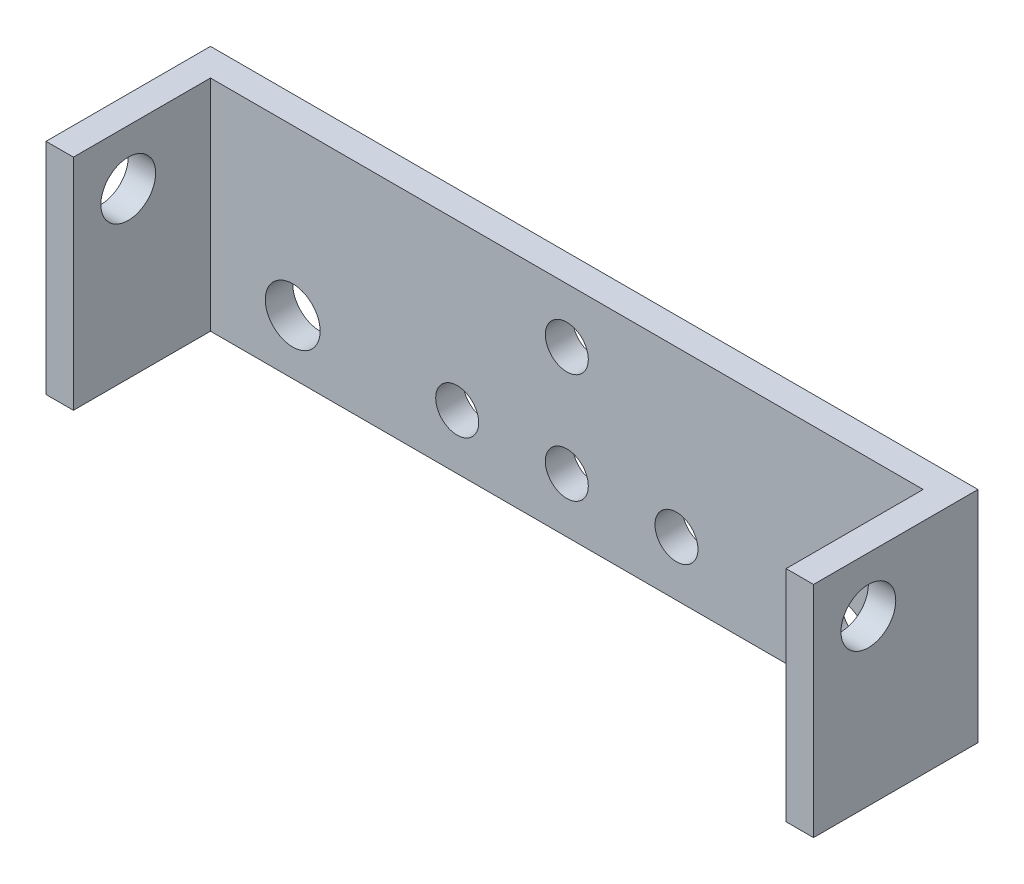
from build123d import *

# Parameters (mm, degrees)
BOSS_EXTRUDE1_DEPTH     = 25.4
SKETCH2_R               = 3.175
CUT_EXTRUDE1_DEPTH      = 89.9
SKETCH3_R               = 3.175
CUT_EXTRUDE2_DEPTH      = 16.875
CUT_EXTRUDE2_DEPTH_BACK = 4.175
SKETCH4_R               = 2.4892
CUT_EXTRUDE3_DEPTH      = 4.175
SKETCH5_R               = 2.4892
CUT_EXTRUDE4_DEPTH      = 20.05


with BuildPart() as part:
    # Sketch1 → Boss-Extrude1 (new body)
    with BuildSketch(Plane(origin=(0, 0, 0), x_dir=(1, 0, 0), z_dir=(0, 1, 0))):
        Polygon((0, 0), (0, 19.05), (88.9, 19.05), (88.9, 0), (85.725, 0), (85.725, 15.875), (3.175, 15.875), (3.175, 0), align=None)
    extrude(amount=BOSS_EXTRUDE1_DEPTH)

    # Sketch2 → Cut-Extrude1 (cut, through all)
    with BuildSketch(Plane(origin=(88.9, 0, 0), x_dir=(0, 0, -1), z_dir=(1, 0, 0))):
        with Locations((6.35, 19.05)):
            Circle(SKETCH2_R)
    extrude(amount=-CUT_EXTRUDE1_DEPTH, mode=Mode.SUBTRACT)

    # Sketch3 → Cut-Extrude2 (cut, two sides)
    with BuildSketch(Plane.XY.offset(-15.875)) as cut_extrude2_sk:
        with Locations((12.7, 6.35)):
            Circle(SKETCH3_R)
        with Locations((76.2, 6.35)):
            Circle(SKETCH3_R)
    extrude(amount=CUT_EXTRUDE2_DEPTH, mode=Mode.SUBTRACT)
    extrude(cut_extrude2_sk.sketch, amount=-CUT_EXTRUDE2_DEPTH_BACK, mode=Mode.SUBTRACT)

    # Sketch4 → Cut-Extrude3 (cut, through all)
    with BuildSketch(Plane.XY.offset(-15.875)):
        with Locations((44.45, 19.05)):
            Circle(SKETCH4_R)
        with Locations((44.45, 6.35)):
            Circle(SKETCH4_R)
    extrude(amount=-CUT_EXTRUDE3_DEPTH, mode=Mode.SUBTRACT)

    # Sketch5 → Cut-Extrude4 (cut, through all)
    with BuildSketch(Plane(origin=(0, 0, -19.05), x_dir=(-1, 0, 0), z_dir=(0, 0, -1))):
        with Locations((-31.75, 6.35)):
            Circle(SKETCH5_R)
        with Locations((-57.15, 6.35)):
            Circle(SKETCH5_R)
    extrude(amount=-CUT_EXTRUDE4_DEPTH, mode=Mode.SUBTRACT)


solid = part.part
